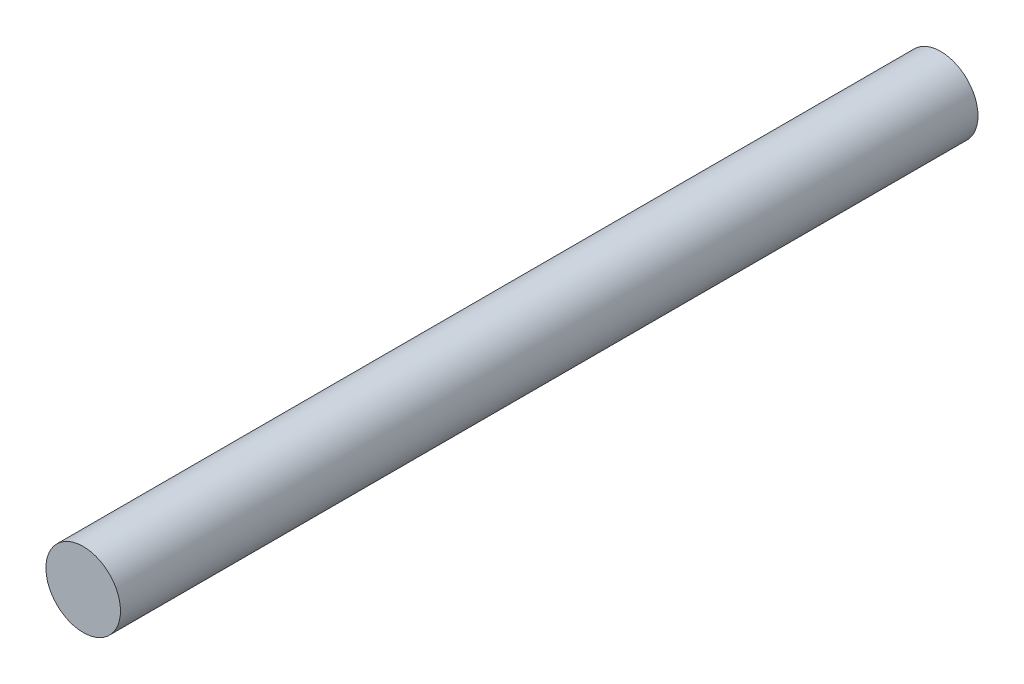
from build123d import *

# Parameters (mm, degrees)
SKETCH1_R           = 4
BOSS_EXTRUDE1_DEPTH = 92


with BuildPart() as part:
    # Sketch1 → Boss-Extrude1 (new body)
    with BuildSketch(Plane.XY):
        Circle(SKETCH1_R)
    extrude(amount=BOSS_EXTRUDE1_DEPTH)


solid = part.part
